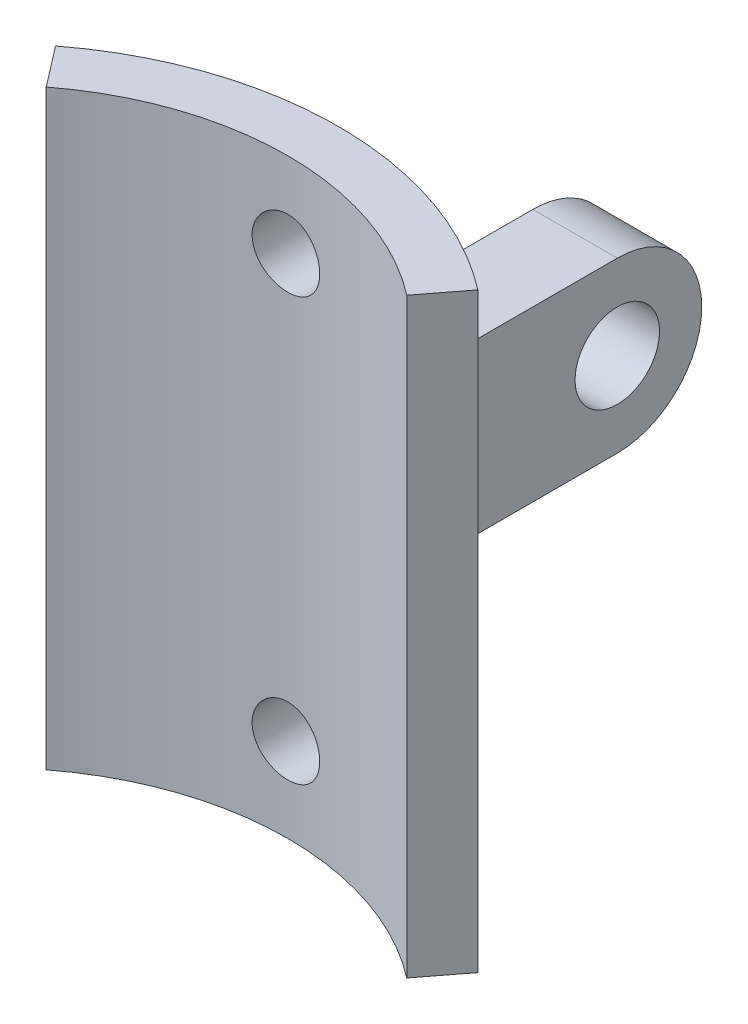
from build123d import *

# Parameters (mm, degrees)
SKETCH2_R                = 20.5
SKETCH2_R_2              = 17.5
BOSS_EXTRUDE1_DEPTH      = 35
SKETCH3_OUTSIDE_W        = 56.546
SKETCH3_OUTSIDE_H        = 56.546
CUT_EXTRUDE1_DEPTH       = 46.447772223
SKETCH5_R                = 2
CUT_EXTRUDE2_DEPTH       = 43.444080859
BOSS_EXTRUDE2_DEPTH      = 2.5
BOSS_EXTRUDE2_DEPTH_BACK = 2.5
SKETCH10_R               = 2.5
CUT_EXTRUDE3_DEPTH       = 55.865745324
FILLET2_R                = 2


with BuildPart() as part:
    # Sketch2 → Boss-Extrude1 (new body)
    with BuildSketch(Plane(origin=(0, 0, 0), x_dir=(1, 0, 0), z_dir=(0, 1, 0))):
        Circle(SKETCH2_R)
        Circle(SKETCH2_R_2, mode=Mode.SUBTRACT)
    extrude(amount=BOSS_EXTRUDE1_DEPTH)

    # Sketch3 outside → Cut-Extrude1 (cut, through all)
    with BuildSketch(Plane(origin=(0, 35, 0), x_dir=(1, 0, 0), z_dir=(0, 1, 0))):
        Rectangle(SKETCH3_OUTSIDE_W, SKETCH3_OUTSIDE_H)
        with BuildLine():
            Line((0, 0), (12.5, 16.248076809))
            ThreePointArc((12.5, 16.248076809), (0, 20.5), (-12.5, 16.248076809))
            Line((-12.5, 16.248076809), (0, 0))
        make_face(mode=Mode.SUBTRACT)
    extrude(amount=-CUT_EXTRUDE1_DEPTH, mode=Mode.SUBTRACT)

    # Sketch5 → Cut-Extrude2 (cut, through all)
    with BuildSketch(Plane.XY):
        with Locations((0, 30)):
            Circle(SKETCH5_R)
        with Locations((0, 5)):
            Circle(SKETCH5_R)
    extrude(amount=-CUT_EXTRUDE2_DEPTH, mode=Mode.SUBTRACT)

    # Sketch7 → Boss-Extrude2 (add, two sides: drawn at the far end of the back side and taken through both)
    with BuildSketch(Plane(origin=(0, 15, 0), x_dir=(0, 1, 0), z_dir=(-1, 0, 0)).offset(-BOSS_EXTRUDE2_DEPTH_BACK)):
        with BuildLine():
            Line((-2.5, 34.5), (-2.5, 18.5))
            Line((-2.5, 18.5), (7.5, 18.5))
            Line((7.5, 18.5), (7.5, 34.5))
            ThreePointArc((7.5, 34.5), (2.5, 39.5), (-2.5, 34.5))
        make_face()
    extrude(amount=BOSS_EXTRUDE2_DEPTH + BOSS_EXTRUDE2_DEPTH_BACK)

    # Sketch10 → Cut-Extrude3 (cut, through all)
    with BuildSketch(Plane(origin=(-2.5, 0, 0), x_dir=(0, 1, 0), z_dir=(-1, 0, 0))):
        with Locations((17.5, 34.5)):
            Circle(SKETCH10_R)
    extrude(amount=-CUT_EXTRUDE3_DEPTH, mode=Mode.SUBTRACT)

    # Fillet2
    fillet2_edges = [part.edges().sort_by_distance(p)[0] for p in [
        (-2.5, 17.5, -20.346989949),
        (0, 22.5, -20.5),
        (2.5, 17.5, -20.346989949),
        (0, 12.5, -20.5),
    ]]
    fillet(fillet2_edges, radius=FILLET2_R)


solid = part.part
